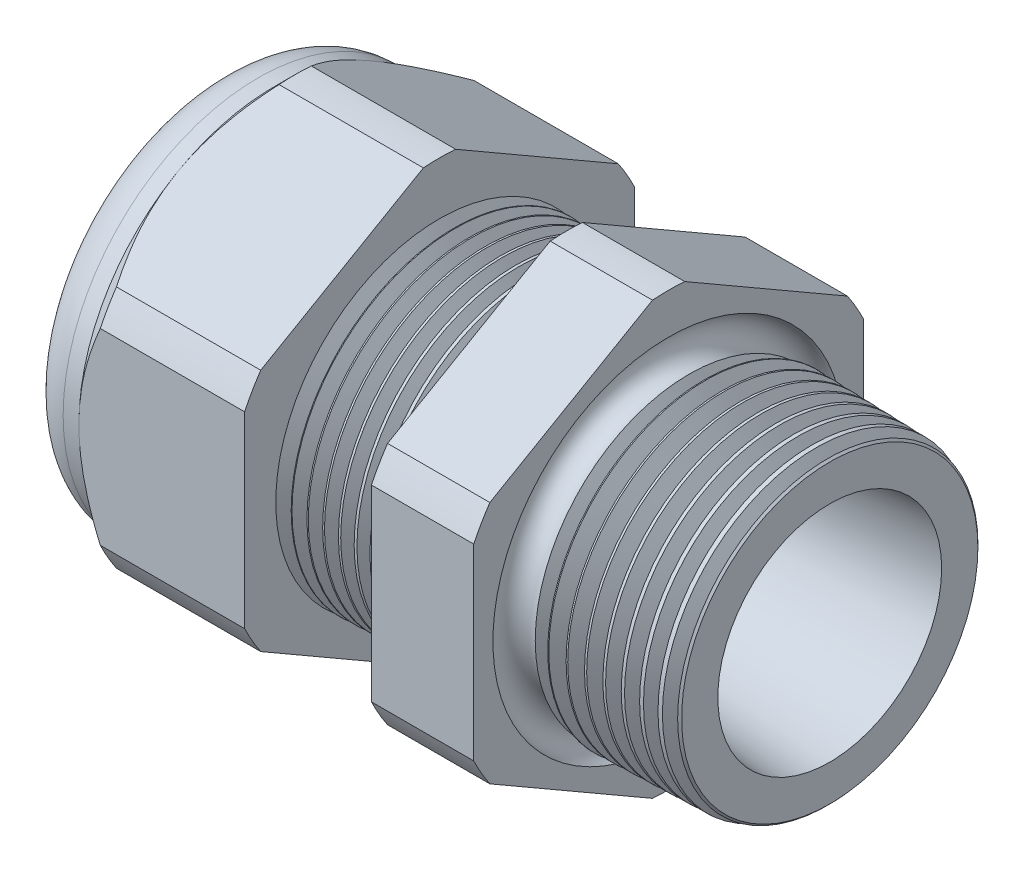
from build123d import *

# Parameters (mm, degrees)
SKETCH12_OUTSIDE_W = 52.432
SKETCH12_OUTSIDE_H = 52.432
CUT_EXTRUDE2_DEPTH = 28.172
FILLET4_R          = 2.032
SKETCH19_OUTSIDE_W = 33.316
SKETCH19_OUTSIDE_H = 35.412
SKETCH19_OUTSIDE_R = 9.525
CUT_EXTRUDE3_DEPTH = 1.999996
CUT_EXTRUDE3_DRAFT = -45
CHAMFER1_SIZE      = 0.260919487
CHAMFER1_SIZE2     = 0.254
SKETCH21_R         = 3.937
PLUG_DEPTH         = 3.81
SKETCH22_R         = 3.683
CUT_EXTRUDE4_DEPTH = 0.508
SKETCH27_R         = 0.762
PLUGHOLES_DEPTH    = 30.464
CIRPATTERN1_COUNT  = 9
SKETCH28_R         = 0.762
MIDHOLE_DEPTH      = 30.464
LPATTERN1_COUNT    = 8
LPATTERN1_PITCH    = 0.762
LPATTERN2_COUNT    = 9
LPATTERN2_PITCH    = 0.889
SKETCH32_R         = 0.889


with BuildPart() as part:
    # Sketch10 → Revolve2 (revolve)
    with BuildSketch(Plane.XY, mode=Mode.PRIVATE) as revolve2_sk:
        Polygon((-29.972, 3.937), (-19.072, 3.937), (0, 5.469582104), (0, 7.501582104), (-7.874, 7.70777005), (-7.874, 19.05), (-12.874, 19.05), (-12.874, 7.838699658), (-19.072, 8.001), (-19.072, 19.05), (-27.172, 19.05), (-27.172, 9.525), (-29.972, 9.525), align=None)
    revolve(revolve2_sk.sketch.rotate(Axis((0, 0, 0), (-1, 0, 0)), 90), axis=Axis((0, 0, 0), (-1, 0, 0)))  # turned: the seam where the file's is

    # Sketch12 outside → Cut-Extrude2 (cut, through all)
    with BuildSketch(Plane.ZY.offset(27.172)):
        Rectangle(SKETCH12_OUTSIDE_W, SKETCH12_OUTSIDE_H)
        with BuildLine():
            Line((-0.788451287, 10.543310065), (-8.736548713, 5.954473877))
            ThreePointArc((-8.736548713, 5.954473877), (-9.156270088, 5.286375), (-9.525, 4.588836188))
            Line((-9.525, 4.588836188), (-9.525, -4.588836188))
            ThreePointArc((-9.525, -4.588836188), (-9.156270088, -5.286375), (-8.736548713, -5.954473877))
            Line((-8.736548713, -5.954473877), (-0.788451287, -10.543310065))
            ThreePointArc((-0.788451287, -10.543310065), (0, -10.57275), (0.788451287, -10.543310065))
            Line((0.788451287, -10.543310065), (8.736548713, -5.954473877))
            ThreePointArc((8.736548713, -5.954473877), (9.156270088, -5.286375), (9.525, -4.588836188))
            Line((9.525, -4.588836188), (9.525, 4.588836188))
            ThreePointArc((9.525, 4.588836188), (9.156270088, 5.286375), (8.736548713, 5.954473877))
            Line((8.736548713, 5.954473877), (0.788451287, 10.543310065))
            ThreePointArc((0.788451287, 10.543310065), (0, 10.57275), (-0.788451287, 10.543310065))
        make_face(mode=Mode.SUBTRACT)
    extrude(amount=-CUT_EXTRUDE2_DEPTH, mode=Mode.SUBTRACT)

    # Fillet4
    fillet4_edges = [part.edges().sort_by_distance(p)[0] for p in [
        (-29.972, 0, 9.525),
    ]]
    fillet(fillet4_edges, radius=FILLET4_R)


with BuildPart() as cut_extrude3_tool:
    # Sketch19 outside → Cut-Extrude3 (with draft: the straight prism first)
    with BuildSketch(Plane.ZY.offset(27.172)):
        Rectangle(SKETCH19_OUTSIDE_W, SKETCH19_OUTSIDE_H)
        Circle(SKETCH19_OUTSIDE_R, mode=Mode.SUBTRACT)
    extrude(amount=-CUT_EXTRUDE3_DEPTH)
    # Cut-Extrude3: the draft: its side faces are tilted about the plane it starts from
    cut_extrude3_sides = [cut_extrude3_tool.faces().sort_by_distance(p)[0] for p in [
        (-26.172002, -17.706, 0),
        (-26.172002, 0, 16.658),
        (-26.172002, 17.706, 0),
        (-26.172002, 0, -16.658),
        (-26.172002, 0, -9.525),
    ]]
    draft(cut_extrude3_sides, Plane.ZY.offset(27.172), CUT_EXTRUDE3_DRAFT)


with BuildPart() as part_1:
    add(part.part)

    # Cut-Extrude3: cut by cut_extrude3_tool
    add(cut_extrude3_tool.part, mode=Mode.SUBTRACT)

    # Chamfer1
    chamfer1_edges = [part_1.edges().sort_by_distance(p)[0] for p in [
        (0, 0, 7.501582104),
    ]]
    chamfer1_side = [part_1.faces().sort_by_distance(p)[0] for p in [
        (0, 0, 5.681758887),
    ]]
    chamfer(chamfer1_edges, length=CHAMFER1_SIZE, length2=CHAMFER1_SIZE2, reference=chamfer1_side[0])

    # Sketch29 → Cut-Revolve1 (revolve, cut)
    with BuildSketch(Plane.XY, mode=Mode.PRIVATE) as cut_revolve1_sk:
        Polygon((-19.072, 8.001), (-18.339016419, 7.981806149), (-18.722130572, 7.356620673), align=None)
    cut_revolve1 = revolve(cut_revolve1_sk.sketch.rotate(Axis((0, 0, 0), (-1, 0, 0)), 90), axis=Axis((0, 0, 0), (-1, 0, 0)), mode=Mode.SUBTRACT)  # turned: the seam where the file's is

    # LPattern1: Cut-Revolve1 ×8
    with Locations(*[(i * LPATTERN1_PITCH, 0, 0) for i in range(1, LPATTERN1_COUNT)]):
        add(cut_revolve1, mode=Mode.SUBTRACT)

    # Sketch30 → Cut-Revolve2 (revolve, cut)
    with BuildSketch(Plane.XY, mode=Mode.PRIVATE) as cut_revolve2_sk:
        Polygon((-7.874, 7.70777005), (-6.994419703, 7.68473743), (-7.454156686, 6.934514858), align=None)
    cut_revolve2 = revolve(cut_revolve2_sk.sketch.rotate(Axis((0, 0, 0), (-1, 0, 0)), 270), axis=Axis((0, 0, 0), (-1, 0, 0)), mode=Mode.SUBTRACT)  # turned: the seam where the file's is

    # LPattern2: Cut-Revolve2 ×9
    with Locations(*[(i * LPATTERN2_PITCH, 0, 0) for i in range(1, LPATTERN2_COUNT)]):
        add(cut_revolve2, mode=Mode.SUBTRACT)

    # Sketch32 → Cut-Revolve3 (revolve, cut)
    with BuildSketch(Plane.XY, mode=Mode.PRIVATE) as cut_revolve3_sk:
        with Locations((-7.747, 7.70777005)):
            Circle(SKETCH32_R)
    revolve(cut_revolve3_sk.sketch.rotate(Axis((0, 0, 0), (-1, 0, 0)), 270), axis=Axis((0, 0, 0), (-1, 0, 0)), mode=Mode.SUBTRACT)  # turned: the seam where the file's is


with BuildPart() as body_2:
    # Sketch21 → plug (new body)
    with BuildSketch(Plane.ZY.offset(29.972)):
        Circle(SKETCH21_R)
    extrude(amount=-PLUG_DEPTH)

    # Sketch22 → Cut-Extrude4 (cut)
    with BuildSketch(Plane.ZY.offset(29.972)):
        Circle(SKETCH22_R)
    extrude(amount=-CUT_EXTRUDE4_DEPTH, mode=Mode.SUBTRACT)

    # Sketch27 → plugholes (cut, through all)
    with BuildSketch(Plane.ZY.offset(29.464)):
        with Locations((-2.917952, 0)):
            Circle(SKETCH27_R)
    plugholes = extrude(amount=-PLUGHOLES_DEPTH, mode=Mode.SUBTRACT)

    # CirPattern1: plugholes ×9 about axis
    cirpattern1_axis = Axis((0, 0, 0), (1, 0, 0))
    for i in range(1, CIRPATTERN1_COUNT):
        add(plugholes.rotate(cirpattern1_axis, i * 360 / CIRPATTERN1_COUNT), mode=Mode.SUBTRACT)

    # Sketch28 → midhole (cut, through all)
    with BuildSketch(Plane.ZY.offset(29.464)):
        Circle(SKETCH28_R)
    extrude(amount=-MIDHOLE_DEPTH, mode=Mode.SUBTRACT)


solid = Compound([part_1.part, body_2.part])
